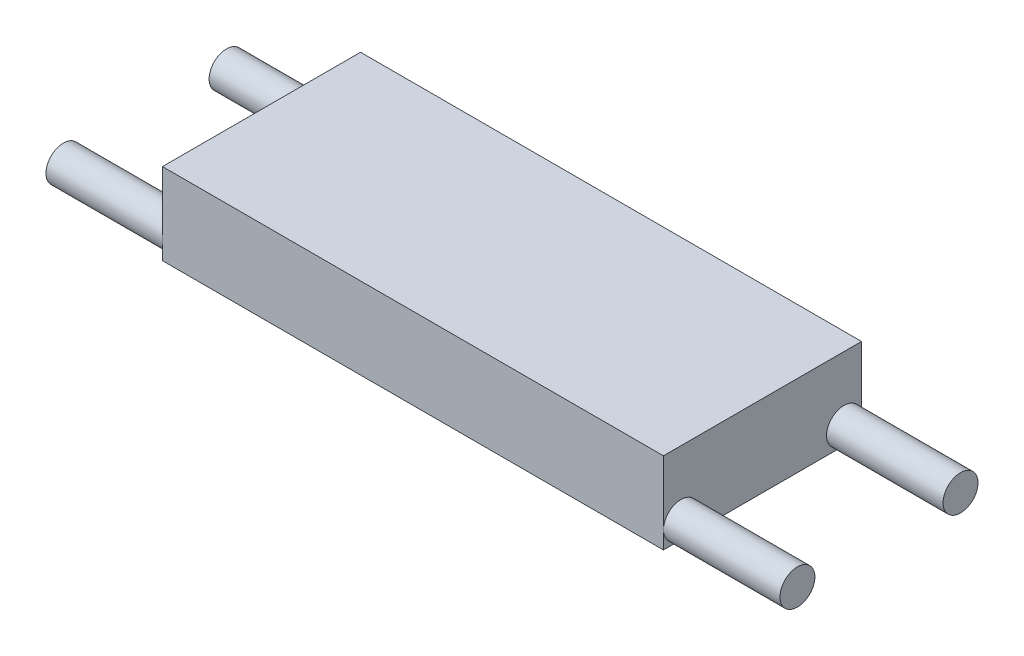
from build123d import *

# Parameters (mm, degrees)
SKETCH1_W           = 43
SKETCH1_H           = 17
BOSS_EXTRUDE1_DEPTH = 7
SKETCH2_R           = 1.5
BOSS_EXTRUDE2_DEPTH = 10


with BuildPart() as part:
    # Sketch1 → Boss-Extrude1 (new body)
    with BuildSketch(Plane(origin=(0, 0, 0), x_dir=(1, 0, 0), z_dir=(0, 1, 0))):
        with Locations((21.5, 8.5)):
            Rectangle(SKETCH1_W, SKETCH1_H)
    extrude(amount=BOSS_EXTRUDE1_DEPTH)

    # Sketch2 → Boss-Extrude2 (add)
    with BuildSketch(Plane(origin=(43, 0, 0), x_dir=(0, 0, -1), z_dir=(1, 0, 0))):
        with Locations((15.5, 1.5)):
            Circle(SKETCH2_R)
        with Locations((1.5, 1.5)):
            Circle(SKETCH2_R)
    boss_extrude2 = extrude(amount=BOSS_EXTRUDE2_DEPTH)

    # Mirror1: Boss-Extrude2 across plane
    add(boss_extrude2.mirror(Plane(origin=(21.5, 0, 0), x_dir=(0, 0, 1), z_dir=(1, 0, 0))))


solid = part.part
